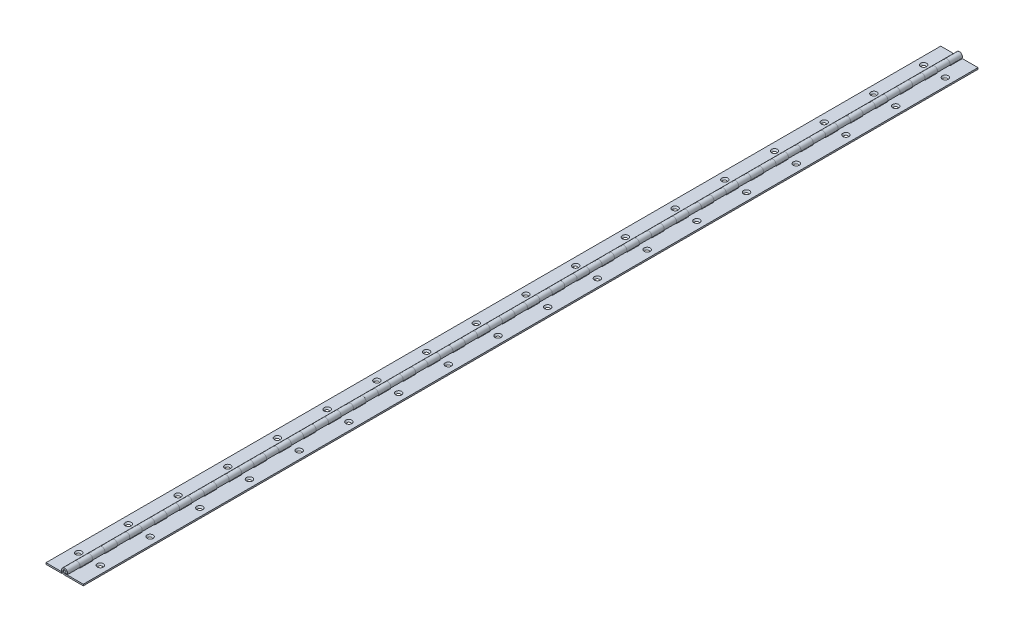
from build123d import *

# Parameters (mm, degrees)
EXTRUDE1_DEPTH           = 457.2
SKETCH3_W                = 6.223
SKETCH3_H                = 12.7
CUT_EXTRUDE1_DEPTH       = 25.4
LPATTERN1_COUNT          = 36
LPATTERN1_PITCH          = 25.4
EXTRUDE2_DEPTH           = 12.7
LPATTERN3_COUNT          = 36
LPATTERN3_PITCH          = 25.4
SKETCH6_W                = 15.9131
SKETCH6_H                = 1.524
EXTRUDE5_DEPTH           = 914.4
SKETCH10_R               = 1.7526
CUT_EXTRUDE2_DEPTH       = 7.223
CUT_EXTRUDE2_TAPER       = -41
LPATTERN4_COUNT          = 18
LPATTERN4_PITCH          = 50.8
MIRROR3_COPY_1_SKETCH_R  = 1.7526
MIRROR3_COPY_1_DEPTH     = 7.223
MIRROR3_COPY_1_TAPER     = -41
MIRROR3_COPY_2_SKETCH_R  = 1.7526
MIRROR3_COPY_2_DEPTH     = 7.223
MIRROR3_COPY_2_TAPER     = -41
MIRROR3_COPY_3_SKETCH_R  = 1.7526
MIRROR3_COPY_3_DEPTH     = 7.223
MIRROR3_COPY_3_TAPER     = -41
MIRROR3_COPY_4_SKETCH_R  = 1.7526
MIRROR3_COPY_4_DEPTH     = 7.223
MIRROR3_COPY_4_TAPER     = -41
MIRROR3_COPY_5_SKETCH_R  = 1.7526
MIRROR3_COPY_5_DEPTH     = 7.223
MIRROR3_COPY_5_TAPER     = -41
MIRROR3_COPY_6_SKETCH_R  = 1.7526
MIRROR3_COPY_6_DEPTH     = 7.223
MIRROR3_COPY_6_TAPER     = -41
MIRROR3_COPY_7_SKETCH_R  = 1.7526
MIRROR3_COPY_7_DEPTH     = 7.223
MIRROR3_COPY_7_TAPER     = -41
MIRROR3_COPY_8_SKETCH_R  = 1.7526
MIRROR3_COPY_8_DEPTH     = 7.223
MIRROR3_COPY_8_TAPER     = -41
MIRROR3_COPY_9_SKETCH_R  = 1.7526
MIRROR3_COPY_9_DEPTH     = 7.223
MIRROR3_COPY_9_TAPER     = -41
MIRROR3_COPY_10_SKETCH_R = 1.7526
MIRROR3_COPY_10_DEPTH    = 7.223
MIRROR3_COPY_10_TAPER    = -41
MIRROR3_COPY_11_SKETCH_R = 1.7526
MIRROR3_COPY_11_DEPTH    = 7.223
MIRROR3_COPY_11_TAPER    = -41
MIRROR3_COPY_12_SKETCH_R = 1.7526
MIRROR3_COPY_12_DEPTH    = 7.223
MIRROR3_COPY_12_TAPER    = -41
MIRROR3_COPY_13_SKETCH_R = 1.7526
MIRROR3_COPY_13_DEPTH    = 7.223
MIRROR3_COPY_13_TAPER    = -41
MIRROR3_COPY_14_SKETCH_R = 1.7526
MIRROR3_COPY_14_DEPTH    = 7.223
MIRROR3_COPY_14_TAPER    = -41
MIRROR3_COPY_15_SKETCH_R = 1.7526
MIRROR3_COPY_15_DEPTH    = 7.223
MIRROR3_COPY_15_TAPER    = -41
MIRROR3_COPY_16_SKETCH_R = 1.7526
MIRROR3_COPY_16_DEPTH    = 7.223
MIRROR3_COPY_16_TAPER    = -41
MIRROR3_COPY_17_SKETCH_R = 1.7526
MIRROR3_COPY_17_DEPTH    = 7.223
MIRROR3_COPY_17_TAPER    = -41
SKETCH7_R                = 1.5875
EXTRUDE4_DEPTH           = 457.2
CHAMFER1_SIZE            = 0.3175


with BuildPart() as part:
    # Sketch2 → Extrude1 (new body, symmetric)
    with BuildSketch(Plane.XY):
        with BuildLine():
            Line((19.05, -1.5875), (19.05, -3.1115))
            Line((19.05, -3.1115), (0, -3.1115))
            ThreePointArc((0, -3.1115), (-1.671807731, 2.624212484), (2.819976679, -1.314976721))
            Line((2.819976679, -1.314976721), (1.438763612, -0.670906491))
            ThreePointArc((1.438763612, -0.670906491), (-0.852963128, 1.33888392), (0, -1.5875))
            Line((0, -1.5875), (19.05, -1.5875))
        make_face()
    extrude(amount=EXTRUDE1_DEPTH, both=True)

    # Sketch3 → Cut-Extrude1 (cut, symmetric)
    with BuildSketch(Plane(origin=(0, -1.5875, 0), x_dir=(1, 0, 0), z_dir=(0, 1, 0))):
        with Locations((0, 450.85)):
            Rectangle(SKETCH3_W, SKETCH3_H)
    cut_extrude1 = extrude(amount=CUT_EXTRUDE1_DEPTH, both=True, mode=Mode.SUBTRACT)

    # LPattern1: Cut-Extrude1 ×36
    with Locations(*[(0, 0, i * LPATTERN1_PITCH) for i in range(1, LPATTERN1_COUNT)]):
        add(cut_extrude1, mode=Mode.SUBTRACT)

    # Sketch10 → Cut-Extrude2 (cut, through all)
    with BuildSketch(Plane(origin=(0, -3.1115, 0), x_dir=(1, 0, 0), z_dir=(0, 1, 0))):
        with Locations((11.1125, 431.8)):
            Circle(SKETCH10_R)
    cut_extrude2 = extrude(amount=CUT_EXTRUDE2_DEPTH, taper=CUT_EXTRUDE2_TAPER, mode=Mode.SUBTRACT)

    # LPattern4: Cut-Extrude2 ×18
    with Locations(*[(0, 0, i * LPATTERN4_PITCH) for i in range(1, LPATTERN4_COUNT)]):
        add(cut_extrude2, mode=Mode.SUBTRACT)


with BuildPart() as body_2:
    # Sketch5 → Extrude2 (new body)
    with BuildSketch(Plane(origin=(0, 0, -457.2), x_dir=(-1, 0, 0), z_dir=(0, 0, -1))):
        with BuildLine():
            Line((0, -1.5875), (19.05, -1.5875))
            Line((19.05, -1.5875), (19.05, -3.1115))
            Line((19.05, -3.1115), (0, -3.1115))
            ThreePointArc((0, -3.1115), (-1.671807731, 2.624212484), (2.819976679, -1.314976721))
            Line((2.819976679, -1.314976721), (1.438763612, -0.670906491))
            ThreePointArc((1.438763612, -0.670906491), (-0.852963128, 1.33888392), (0, -1.5875))
        make_face()
    extrude(amount=-EXTRUDE2_DEPTH)


with BuildPart() as lpattern3_1:
    # LPattern3: pattern copy
    add(body_2.part.moved(Location(Vector(0, 0, 1) * (1 * LPATTERN3_PITCH))))


with BuildPart() as lpattern3_2:
    # LPattern3: pattern copy
    add(body_2.part.moved(Location(Vector(0, 0, 1) * (2 * LPATTERN3_PITCH))))


with BuildPart() as lpattern3_3:
    # LPattern3: pattern copy
    add(body_2.part.moved(Location(Vector(0, 0, 1) * (3 * LPATTERN3_PITCH))))


with BuildPart() as lpattern3_4:
    # LPattern3: pattern copy
    add(body_2.part.moved(Location(Vector(0, 0, 1) * (4 * LPATTERN3_PITCH))))


with BuildPart() as lpattern3_5:
    # LPattern3: pattern copy
    add(body_2.part.moved(Location(Vector(0, 0, 1) * (5 * LPATTERN3_PITCH))))


with BuildPart() as lpattern3_6:
    # LPattern3: pattern copy
    add(body_2.part.moved(Location(Vector(0, 0, 1) * (6 * LPATTERN3_PITCH))))


with BuildPart() as lpattern3_7:
    # LPattern3: pattern copy
    add(body_2.part.moved(Location(Vector(0, 0, 1) * (7 * LPATTERN3_PITCH))))


with BuildPart() as lpattern3_8:
    # LPattern3: pattern copy
    add(body_2.part.moved(Location(Vector(0, 0, 1) * (8 * LPATTERN3_PITCH))))


with BuildPart() as lpattern3_9:
    # LPattern3: pattern copy
    add(body_2.part.moved(Location(Vector(0, 0, 1) * (9 * LPATTERN3_PITCH))))


with BuildPart() as lpattern3_10:
    # LPattern3: pattern copy
    add(body_2.part.moved(Location(Vector(0, 0, 1) * (10 * LPATTERN3_PITCH))))


with BuildPart() as lpattern3_11:
    # LPattern3: pattern copy
    add(body_2.part.moved(Location(Vector(0, 0, 1) * (11 * LPATTERN3_PITCH))))


with BuildPart() as lpattern3_12:
    # LPattern3: pattern copy
    add(body_2.part.moved(Location(Vector(0, 0, 1) * (12 * LPATTERN3_PITCH))))


with BuildPart() as lpattern3_13:
    # LPattern3: pattern copy
    add(body_2.part.moved(Location(Vector(0, 0, 1) * (13 * LPATTERN3_PITCH))))


with BuildPart() as lpattern3_14:
    # LPattern3: pattern copy
    add(body_2.part.moved(Location(Vector(0, 0, 1) * (14 * LPATTERN3_PITCH))))


with BuildPart() as lpattern3_15:
    # LPattern3: pattern copy
    add(body_2.part.moved(Location(Vector(0, 0, 1) * (15 * LPATTERN3_PITCH))))


with BuildPart() as lpattern3_16:
    # LPattern3: pattern copy
    add(body_2.part.moved(Location(Vector(0, 0, 1) * (16 * LPATTERN3_PITCH))))


with BuildPart() as lpattern3_17:
    # LPattern3: pattern copy
    add(body_2.part.moved(Location(Vector(0, 0, 1) * (17 * LPATTERN3_PITCH))))


with BuildPart() as lpattern3_18:
    # LPattern3: pattern copy
    add(body_2.part.moved(Location(Vector(0, 0, 1) * (18 * LPATTERN3_PITCH))))


with BuildPart() as lpattern3_19:
    # LPattern3: pattern copy
    add(body_2.part.moved(Location(Vector(0, 0, 1) * (19 * LPATTERN3_PITCH))))


with BuildPart() as lpattern3_20:
    # LPattern3: pattern copy
    add(body_2.part.moved(Location(Vector(0, 0, 1) * (20 * LPATTERN3_PITCH))))


with BuildPart() as lpattern3_21:
    # LPattern3: pattern copy
    add(body_2.part.moved(Location(Vector(0, 0, 1) * (21 * LPATTERN3_PITCH))))


with BuildPart() as lpattern3_22:
    # LPattern3: pattern copy
    add(body_2.part.moved(Location(Vector(0, 0, 1) * (22 * LPATTERN3_PITCH))))


with BuildPart() as lpattern3_23:
    # LPattern3: pattern copy
    add(body_2.part.moved(Location(Vector(0, 0, 1) * (23 * LPATTERN3_PITCH))))


with BuildPart() as lpattern3_24:
    # LPattern3: pattern copy
    add(body_2.part.moved(Location(Vector(0, 0, 1) * (24 * LPATTERN3_PITCH))))


with BuildPart() as lpattern3_25:
    # LPattern3: pattern copy
    add(body_2.part.moved(Location(Vector(0, 0, 1) * (25 * LPATTERN3_PITCH))))


with BuildPart() as lpattern3_26:
    # LPattern3: pattern copy
    add(body_2.part.moved(Location(Vector(0, 0, 1) * (26 * LPATTERN3_PITCH))))


with BuildPart() as lpattern3_27:
    # LPattern3: pattern copy
    add(body_2.part.moved(Location(Vector(0, 0, 1) * (27 * LPATTERN3_PITCH))))


with BuildPart() as lpattern3_28:
    # LPattern3: pattern copy
    add(body_2.part.moved(Location(Vector(0, 0, 1) * (28 * LPATTERN3_PITCH))))


with BuildPart() as lpattern3_29:
    # LPattern3: pattern copy
    add(body_2.part.moved(Location(Vector(0, 0, 1) * (29 * LPATTERN3_PITCH))))


with BuildPart() as lpattern3_30:
    # LPattern3: pattern copy
    add(body_2.part.moved(Location(Vector(0, 0, 1) * (30 * LPATTERN3_PITCH))))


with BuildPart() as lpattern3_31:
    # LPattern3: pattern copy
    add(body_2.part.moved(Location(Vector(0, 0, 1) * (31 * LPATTERN3_PITCH))))


with BuildPart() as lpattern3_32:
    # LPattern3: pattern copy
    add(body_2.part.moved(Location(Vector(0, 0, 1) * (32 * LPATTERN3_PITCH))))


with BuildPart() as lpattern3_33:
    # LPattern3: pattern copy
    add(body_2.part.moved(Location(Vector(0, 0, 1) * (33 * LPATTERN3_PITCH))))


with BuildPart() as lpattern3_34:
    # LPattern3: pattern copy
    add(body_2.part.moved(Location(Vector(0, 0, 1) * (34 * LPATTERN3_PITCH))))


with BuildPart() as lpattern3_35:
    # LPattern3: pattern copy
    add(body_2.part.moved(Location(Vector(0, 0, 1) * (35 * LPATTERN3_PITCH))))


with BuildPart() as body_2_1:
    add(body_2.part)

    add(lpattern3_1.part)  # Extrude5 merges LPattern3_1

    add(lpattern3_2.part)  # Extrude5 merges LPattern3_2

    add(lpattern3_3.part)  # Extrude5 merges LPattern3_3

    add(lpattern3_4.part)  # Extrude5 merges LPattern3_4

    add(lpattern3_5.part)  # Extrude5 merges LPattern3_5

    add(lpattern3_6.part)  # Extrude5 merges LPattern3_6

    add(lpattern3_7.part)  # Extrude5 merges LPattern3_7

    add(lpattern3_8.part)  # Extrude5 merges LPattern3_8

    add(lpattern3_9.part)  # Extrude5 merges LPattern3_9

    add(lpattern3_10.part)  # Extrude5 merges LPattern3_10

    add(lpattern3_11.part)  # Extrude5 merges LPattern3_11

    add(lpattern3_12.part)  # Extrude5 merges LPattern3_12

    add(lpattern3_13.part)  # Extrude5 merges LPattern3_13

    add(lpattern3_14.part)  # Extrude5 merges LPattern3_14

    add(lpattern3_15.part)  # Extrude5 merges LPattern3_15

    add(lpattern3_16.part)  # Extrude5 merges LPattern3_16

    add(lpattern3_17.part)  # Extrude5 merges LPattern3_17

    add(lpattern3_18.part)  # Extrude5 merges LPattern3_18

    add(lpattern3_19.part)  # Extrude5 merges LPattern3_19

    add(lpattern3_20.part)  # Extrude5 merges LPattern3_20

    add(lpattern3_21.part)  # Extrude5 merges LPattern3_21

    add(lpattern3_22.part)  # Extrude5 merges LPattern3_22

    add(lpattern3_23.part)  # Extrude5 merges LPattern3_23

    add(lpattern3_24.part)  # Extrude5 merges LPattern3_24

    add(lpattern3_25.part)  # Extrude5 merges LPattern3_25

    add(lpattern3_26.part)  # Extrude5 merges LPattern3_26

    add(lpattern3_27.part)  # Extrude5 merges LPattern3_27

    add(lpattern3_28.part)  # Extrude5 merges LPattern3_28

    add(lpattern3_29.part)  # Extrude5 merges LPattern3_29

    add(lpattern3_30.part)  # Extrude5 merges LPattern3_30

    add(lpattern3_31.part)  # Extrude5 merges LPattern3_31

    add(lpattern3_32.part)  # Extrude5 merges LPattern3_32

    add(lpattern3_33.part)  # Extrude5 merges LPattern3_33

    add(lpattern3_34.part)  # Extrude5 merges LPattern3_34

    add(lpattern3_35.part)  # Extrude5 merges LPattern3_35
    # Sketch6 → Extrude5 (add)
    with BuildSketch(Plane(origin=(0, 0, -457.2), x_dir=(-1, 0, 0), z_dir=(0, 0, -1))):
        with Locations((11.09345, -2.3495)):
            Rectangle(SKETCH6_W, SKETCH6_H)
    extrude(amount=-EXTRUDE5_DEPTH)

    # Mirror3: Cut-Extrude2 across plane
    add(cut_extrude2.mirror(Plane(origin=(0, 0, 0), x_dir=(0, 0, 1), z_dir=(1, 0, 0))), mode=Mode.SUBTRACT)

    # Mirror3 copy 1 sketch → Mirror3 copy 1 (cut, through all)
    with BuildSketch(Plane(origin=(0, -3.1115, 50.8), x_dir=(-1, 0, 0), z_dir=(0, 1, 0))):
        with Locations((11.1125, -431.8)):
            Circle(MIRROR3_COPY_1_SKETCH_R)
    extrude(amount=MIRROR3_COPY_1_DEPTH, taper=MIRROR3_COPY_1_TAPER, mode=Mode.SUBTRACT)

    # Mirror3 copy 2 sketch → Mirror3 copy 2 (cut, through all)
    with BuildSketch(Plane(origin=(0, -3.1115, 101.6), x_dir=(-1, 0, 0), z_dir=(0, 1, 0))):
        with Locations((11.1125, -431.8)):
            Circle(MIRROR3_COPY_2_SKETCH_R)
    extrude(amount=MIRROR3_COPY_2_DEPTH, taper=MIRROR3_COPY_2_TAPER, mode=Mode.SUBTRACT)

    # Mirror3 copy 3 sketch → Mirror3 copy 3 (cut, through all)
    with BuildSketch(Plane(origin=(0, -3.1115, 152.4), x_dir=(-1, 0, 0), z_dir=(0, 1, 0))):
        with Locations((11.1125, -431.8)):
            Circle(MIRROR3_COPY_3_SKETCH_R)
    extrude(amount=MIRROR3_COPY_3_DEPTH, taper=MIRROR3_COPY_3_TAPER, mode=Mode.SUBTRACT)

    # Mirror3 copy 4 sketch → Mirror3 copy 4 (cut, through all)
    with BuildSketch(Plane(origin=(0, -3.1115, 203.2), x_dir=(-1, 0, 0), z_dir=(0, 1, 0))):
        with Locations((11.1125, -431.8)):
            Circle(MIRROR3_COPY_4_SKETCH_R)
    extrude(amount=MIRROR3_COPY_4_DEPTH, taper=MIRROR3_COPY_4_TAPER, mode=Mode.SUBTRACT)

    # Mirror3 copy 5 sketch → Mirror3 copy 5 (cut, through all)
    with BuildSketch(Plane(origin=(0, -3.1115, 254), x_dir=(-1, 0, 0), z_dir=(0, 1, 0))):
        with Locations((11.1125, -431.8)):
            Circle(MIRROR3_COPY_5_SKETCH_R)
    extrude(amount=MIRROR3_COPY_5_DEPTH, taper=MIRROR3_COPY_5_TAPER, mode=Mode.SUBTRACT)

    # Mirror3 copy 6 sketch → Mirror3 copy 6 (cut, through all)
    with BuildSketch(Plane(origin=(0, -3.1115, 304.8), x_dir=(-1, 0, 0), z_dir=(0, 1, 0))):
        with Locations((11.1125, -431.8)):
            Circle(MIRROR3_COPY_6_SKETCH_R)
    extrude(amount=MIRROR3_COPY_6_DEPTH, taper=MIRROR3_COPY_6_TAPER, mode=Mode.SUBTRACT)

    # Mirror3 copy 7 sketch → Mirror3 copy 7 (cut, through all)
    with BuildSketch(Plane(origin=(0, -3.1115, 355.6), x_dir=(-1, 0, 0), z_dir=(0, 1, 0))):
        with Locations((11.1125, -431.8)):
            Circle(MIRROR3_COPY_7_SKETCH_R)
    extrude(amount=MIRROR3_COPY_7_DEPTH, taper=MIRROR3_COPY_7_TAPER, mode=Mode.SUBTRACT)

    # Mirror3 copy 8 sketch → Mirror3 copy 8 (cut, through all)
    with BuildSketch(Plane(origin=(0, -3.1115, 406.4), x_dir=(-1, 0, 0), z_dir=(0, 1, 0))):
        with Locations((11.1125, -431.8)):
            Circle(MIRROR3_COPY_8_SKETCH_R)
    extrude(amount=MIRROR3_COPY_8_DEPTH, taper=MIRROR3_COPY_8_TAPER, mode=Mode.SUBTRACT)

    # Mirror3 copy 9 sketch → Mirror3 copy 9 (cut, through all)
    with BuildSketch(Plane(origin=(0, -3.1115, 457.2), x_dir=(-1, 0, 0), z_dir=(0, 1, 0))):
        with Locations((11.1125, -431.8)):
            Circle(MIRROR3_COPY_9_SKETCH_R)
    extrude(amount=MIRROR3_COPY_9_DEPTH, taper=MIRROR3_COPY_9_TAPER, mode=Mode.SUBTRACT)

    # Mirror3 copy 10 sketch → Mirror3 copy 10 (cut, through all)
    with BuildSketch(Plane(origin=(0, -3.1115, 508), x_dir=(-1, 0, 0), z_dir=(0, 1, 0))):
        with Locations((11.1125, -431.8)):
            Circle(MIRROR3_COPY_10_SKETCH_R)
    extrude(amount=MIRROR3_COPY_10_DEPTH, taper=MIRROR3_COPY_10_TAPER, mode=Mode.SUBTRACT)

    # Mirror3 copy 11 sketch → Mirror3 copy 11 (cut, through all)
    with BuildSketch(Plane(origin=(0, -3.1115, 558.8), x_dir=(-1, 0, 0), z_dir=(0, 1, 0))):
        with Locations((11.1125, -431.8)):
            Circle(MIRROR3_COPY_11_SKETCH_R)
    extrude(amount=MIRROR3_COPY_11_DEPTH, taper=MIRROR3_COPY_11_TAPER, mode=Mode.SUBTRACT)

    # Mirror3 copy 12 sketch → Mirror3 copy 12 (cut, through all)
    with BuildSketch(Plane(origin=(0, -3.1115, 609.6), x_dir=(-1, 0, 0), z_dir=(0, 1, 0))):
        with Locations((11.1125, -431.8)):
            Circle(MIRROR3_COPY_12_SKETCH_R)
    extrude(amount=MIRROR3_COPY_12_DEPTH, taper=MIRROR3_COPY_12_TAPER, mode=Mode.SUBTRACT)

    # Mirror3 copy 13 sketch → Mirror3 copy 13 (cut, through all)
    with BuildSketch(Plane(origin=(0, -3.1115, 660.4), x_dir=(-1, 0, 0), z_dir=(0, 1, 0))):
        with Locations((11.1125, -431.8)):
            Circle(MIRROR3_COPY_13_SKETCH_R)
    extrude(amount=MIRROR3_COPY_13_DEPTH, taper=MIRROR3_COPY_13_TAPER, mode=Mode.SUBTRACT)

    # Mirror3 copy 14 sketch → Mirror3 copy 14 (cut, through all)
    with BuildSketch(Plane(origin=(0, -3.1115, 711.2), x_dir=(-1, 0, 0), z_dir=(0, 1, 0))):
        with Locations((11.1125, -431.8)):
            Circle(MIRROR3_COPY_14_SKETCH_R)
    extrude(amount=MIRROR3_COPY_14_DEPTH, taper=MIRROR3_COPY_14_TAPER, mode=Mode.SUBTRACT)

    # Mirror3 copy 15 sketch → Mirror3 copy 15 (cut, through all)
    with BuildSketch(Plane(origin=(0, -3.1115, 762), x_dir=(-1, 0, 0), z_dir=(0, 1, 0))):
        with Locations((11.1125, -431.8)):
            Circle(MIRROR3_COPY_15_SKETCH_R)
    extrude(amount=MIRROR3_COPY_15_DEPTH, taper=MIRROR3_COPY_15_TAPER, mode=Mode.SUBTRACT)

    # Mirror3 copy 16 sketch → Mirror3 copy 16 (cut, through all)
    with BuildSketch(Plane(origin=(0, -3.1115, 812.8), x_dir=(-1, 0, 0), z_dir=(0, 1, 0))):
        with Locations((11.1125, -431.8)):
            Circle(MIRROR3_COPY_16_SKETCH_R)
    extrude(amount=MIRROR3_COPY_16_DEPTH, taper=MIRROR3_COPY_16_TAPER, mode=Mode.SUBTRACT)

    # Mirror3 copy 17 sketch → Mirror3 copy 17 (cut, through all)
    with BuildSketch(Plane(origin=(0, -3.1115, 863.6), x_dir=(-1, 0, 0), z_dir=(0, 1, 0))):
        with Locations((11.1125, -431.8)):
            Circle(MIRROR3_COPY_17_SKETCH_R)
    extrude(amount=MIRROR3_COPY_17_DEPTH, taper=MIRROR3_COPY_17_TAPER, mode=Mode.SUBTRACT)


with BuildPart() as body_3:
    # Sketch7 → Extrude4 (new body, symmetric)
    with BuildSketch(Plane.XY):
        Circle(SKETCH7_R)
    extrude(amount=EXTRUDE4_DEPTH, both=True)

    # Chamfer1
    chamfer1_edges = [body_3.edges().sort_by_distance(p)[0] for p in [
        (-1.5875, 0, -457.2),
        (-1.5875, 0, 457.2),
    ]]
    chamfer(chamfer1_edges, length=CHAMFER1_SIZE)


solid = Compound([part.part, body_2_1.part, body_3.part])
